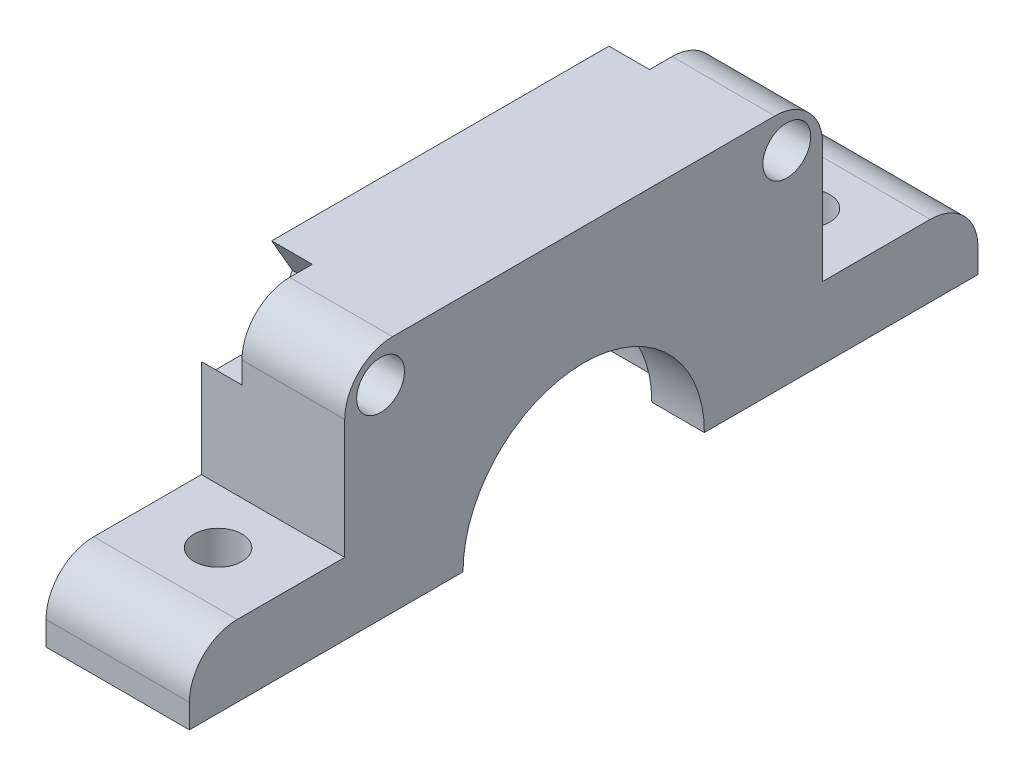
from build123d import *

# Parameters (mm, degrees)
SKETCH1_W           = 6
SKETCH1_H           = 33
BOSS_EXTRUDE1_DEPTH = 3
SKETCH3_W           = 20
SKETCH3_H           = 10
BOSS_EXTRUDE2_DEPTH = 6
FILLET1_R           = 2
CUT_EXTRUDE1_DEPTH  = 43
SKETCH5_R           = 6.05
CUT_EXTRUDE2_DEPTH  = 3.8
FILLET2_R           = 2
SKETCH6_R           = 1
CUT_EXTRUDE3_DEPTH  = 3.8
SKETCH7_R           = 1
CUT_EXTRUDE4_DEPTH  = 15
CUT_EXTRUDE5_DEPTH  = 1.7


with BuildPart() as part:
    # Sketch1 → Boss-Extrude1 (new body)
    with BuildSketch(Plane(origin=(0, 0, 0), x_dir=(1, 0, 0), z_dir=(0, 1, 0))):
        with Locations((6.921568627, 6.794117647)):
            Rectangle(SKETCH1_W, SKETCH1_H)
    extrude(amount=BOSS_EXTRUDE1_DEPTH)

    # Sketch3 → Boss-Extrude2 (add)
    with BuildSketch(Plane(origin=(9.921568627, 0, 0), x_dir=(0, 0, -1), z_dir=(1, 0, 0))):
        with Locations((6.794117647, 5)):
            Rectangle(SKETCH3_W, SKETCH3_H)
    extrude(amount=-BOSS_EXTRUDE2_DEPTH)

    # Fillet1
    fillet1_edges = [part.edges().sort_by_distance(p)[0] for p in [
        (6.921568627, 10, 3.205882353),
        (6.921568627, 10, -16.794117647),
    ]]
    fillet(fillet1_edges, radius=FILLET1_R)

    # Sketch4 → Cut-Extrude1 (cut)
    with BuildSketch(Plane.ZY.offset(-3.921568627)):
        with BuildLine():
            Line((-11.844117647, 0), (-1.744117647, 0))
            ThreePointArc((-1.744117647, 0), (-6.794117647, 5.05), (-11.844117647, 0))
        make_face()
    extrude(amount=-CUT_EXTRUDE1_DEPTH, mode=Mode.SUBTRACT)

    # Sketch5 → Cut-Extrude2 (cut)
    with BuildSketch(Plane.ZY.offset(-3.921568627)):
        with Locations((-6.794117647, 0)):
            Circle(SKETCH5_R)
    extrude(amount=-CUT_EXTRUDE2_DEPTH, mode=Mode.SUBTRACT)

    # Fillet2
    fillet2_edges = [part.edges().sort_by_distance(p)[0] for p in [
        (6.921568627, 3, -23.294117647),
        (6.921568627, 3, 9.705882353),
    ]]
    fillet(fillet2_edges, radius=FILLET2_R)

    # Sketch6 → Cut-Extrude3 (cut)
    with BuildSketch(Plane(origin=(0, 3, 0), x_dir=(1, 0, 0), z_dir=(0, 1, 0))):
        with Locations((6.921568627, -5.505882353)):
            Circle(SKETCH6_R)
        with Locations((6.921568627, 19.094117647)):
            Circle(SKETCH6_R)
    extrude(amount=-CUT_EXTRUDE3_DEPTH, mode=Mode.SUBTRACT)

    # Sketch7 → Cut-Extrude4 (cut)
    with BuildSketch(Plane(origin=(9.921568627, 0, 0), x_dir=(0, 0, -1), z_dir=(1, 0, 0))):
        with Locations((-1.705882353, 8.5)):
            Circle(SKETCH7_R)
        with Locations((15.294117647, 8.5)):
            Circle(SKETCH7_R)
    extrude(amount=-CUT_EXTRUDE4_DEPTH, mode=Mode.SUBTRACT)

    # Sketch8 → Cut-Extrude5 (cut)
    with BuildSketch(Plane.ZY.offset(-3.921568627)):
        Polygon((-0.603518724, 8.5), (0.551181815, 6.5), (2.860582891, 6.5), (4.01528343, 8.5), (2.860582891, 10.5), (0.551181815, 10.5), align=None)
        Polygon((-17.603518724, 8.5), (-16.448818185, 6.5), (-14.139417109, 6.5), (-12.98471657, 8.5), (-14.139417109, 10.5), (-16.448818185, 10.5), align=None)
    extrude(amount=-CUT_EXTRUDE5_DEPTH, mode=Mode.SUBTRACT)


solid = part.part
